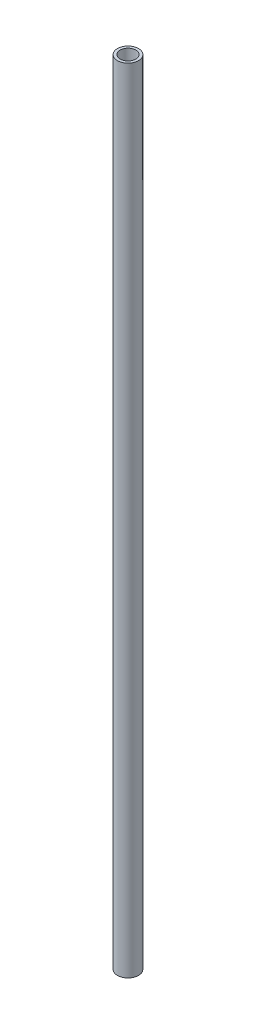
from build123d import *

# Parameters (mm, degrees)
SKETCH1_R           = 2
SKETCH1_R_2         = 1.5
BOSS_EXTRUDE1_DEPTH = 75.5


with BuildPart() as part:
    # Sketch1 → Boss-Extrude1 (new body, symmetric)
    with BuildSketch(Plane(origin=(0, 0, 0), x_dir=(1, 0, 0), z_dir=(0, 1, 0))):
        Circle(SKETCH1_R)
        Circle(SKETCH1_R_2, mode=Mode.SUBTRACT)
    extrude(amount=BOSS_EXTRUDE1_DEPTH, both=True)


solid = part.part
